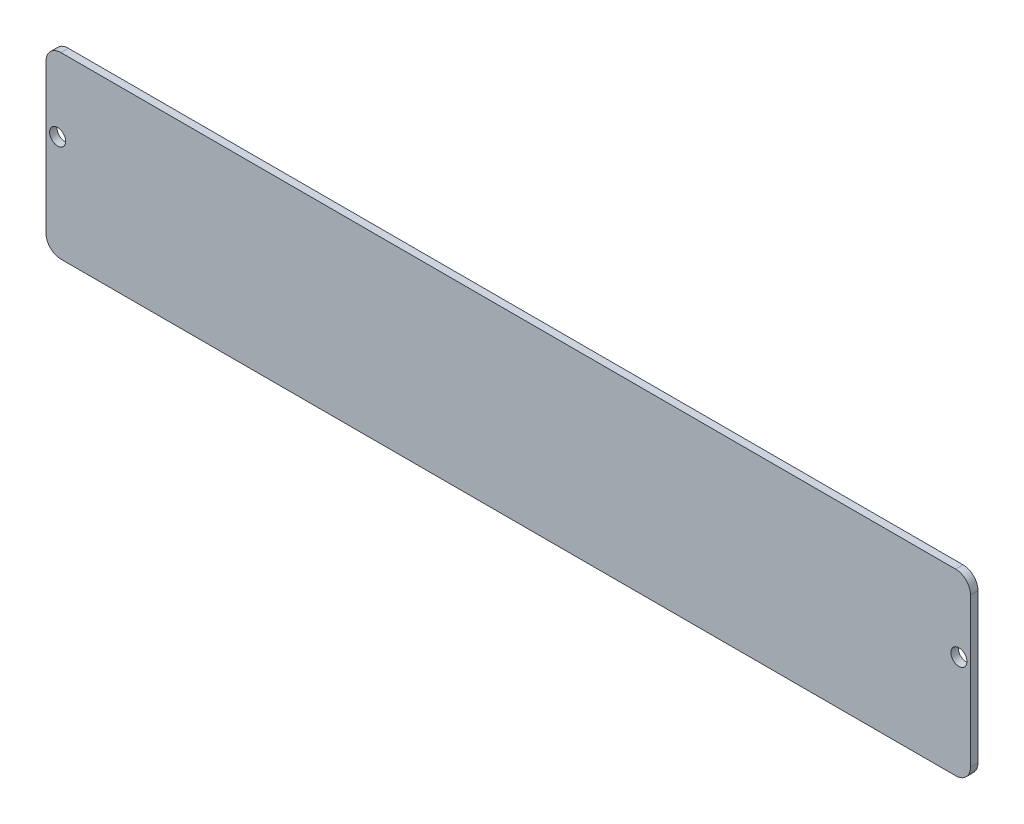
from build123d import *

# Parameters (mm, degrees)
SKETCH1_R           = 3.429
BOSS_EXTRUDE1_DEPTH = 3.175


with BuildPart() as part:
    # Sketch1 → Boss-Extrude1 (new body)
    with BuildSketch(Plane.XY):
        with BuildLine():
            Line((-196.85, 69.85), (-196.85, 6.35))
            ThreePointArc((-196.85, 6.35), (-194.990128061, 1.859871939), (-190.5, 0))
            Line((-190.5, 0), (190.5, 0))
            ThreePointArc((190.5, 0), (194.990128061, 1.859871939), (196.85, 6.35))
            Line((196.85, 6.35), (196.85, 69.85))
            ThreePointArc((196.85, 69.85), (194.990128061, 74.340128061), (190.5, 76.2))
            Line((190.5, 76.2), (-190.5, 76.2))
            ThreePointArc((-190.5, 76.2), (-194.990128061, 74.340128061), (-196.85, 69.85))
        make_face()
        with Locations((191.897, 44.45)):
            Circle(SKETCH1_R, mode=Mode.SUBTRACT)
        with Locations((-191.897, 44.45)):
            Circle(SKETCH1_R, mode=Mode.SUBTRACT)
    extrude(amount=BOSS_EXTRUDE1_DEPTH)


solid = part.part
